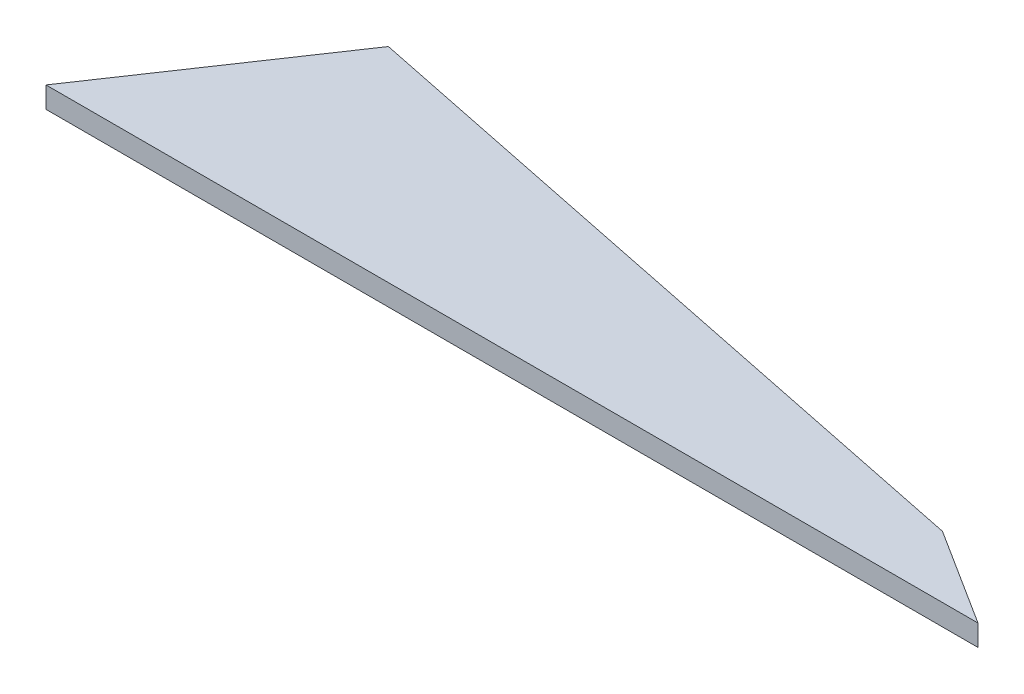
from build123d import *

# Parameters (mm, degrees)
BOSS_EXTRU_1_DEPTH = 2


with BuildPart() as part:
    # Esquisse1 → Boss.-Extru.1 (new body)
    with BuildSketch(Plane(origin=(0, 0, 0), x_dir=(1, 0, 0), z_dir=(0, 1, 0))):
        Polygon((88.04907517, 0), (78.860999726, 5.829838139), (13.030695145, 19.31445401), (0, 0), align=None)
    extrude(amount=BOSS_EXTRU_1_DEPTH)


solid = part.part
